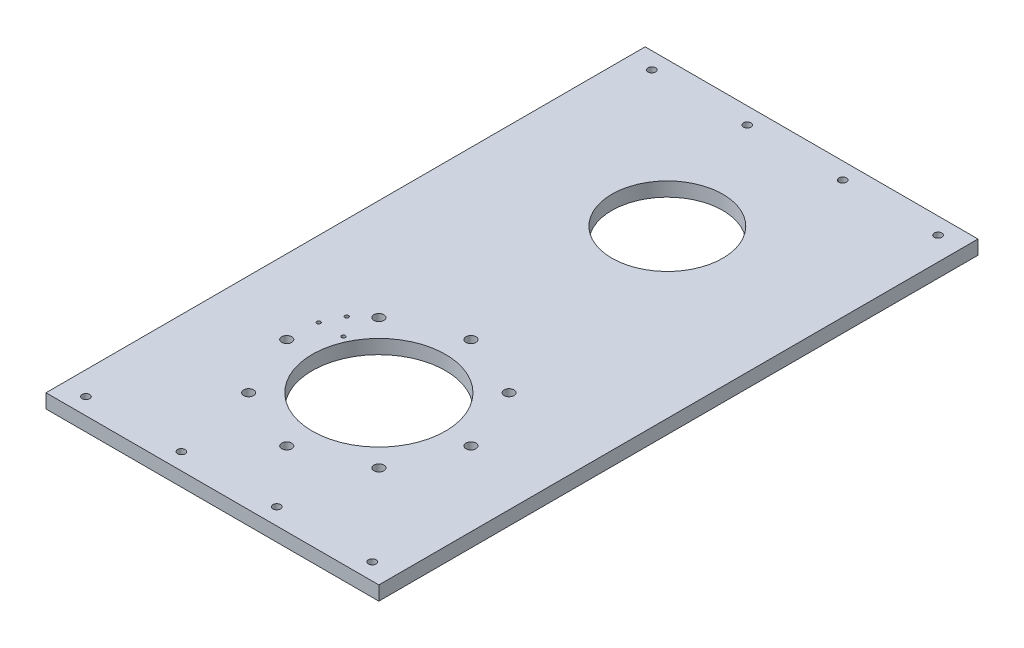
from build123d import *

# Parameters (mm, degrees)
SKETCH1_W           = 150
SKETCH1_H           = 270
BOSS_EXTRUDE1_DEPTH = 6.35
SKETCH2_R           = 2.25
SKETCH2_R_2         = 30
CUT_EXTRUDE1_DEPTH  = 7.35
SKETCH6_R           = 0.85
CUT_EXTRUDE5_DEPTH  = 7.35
SKETCH7_R           = 1.7
CUT_EXTRUDE6_DEPTH  = 7.35
SKETCH8_R           = 25
CUT_EXTRUDE9_DEPTH  = 7.35


with BuildPart() as part:
    # Sketch1 → Boss-Extrude1 (new body)
    with BuildSketch(Plane(origin=(0, 0, 0), x_dir=(1, 0, 0), z_dir=(0, 1, 0))):
        Rectangle(SKETCH1_W, SKETCH1_H)
    extrude(amount=BOSS_EXTRUDE1_DEPTH)

    # Sketch2 → Cut-Extrude1 (cut, through all)
    with BuildSketch(Plane(origin=(0, 6.35, 0), x_dir=(1, 0, 0), z_dir=(0, 1, 0))):
        with Locations((0, -18.5)):
            Circle(SKETCH2_R)
        with Locations((29.344931419, -30.655068581)):
            Circle(SKETCH2_R)
        with Locations((41.5, -60)):
            Circle(SKETCH2_R)
        with Locations((29.344931419, -89.344931419)):
            Circle(SKETCH2_R)
        with Locations((0, -101.5)):
            Circle(SKETCH2_R)
        with Locations((-29.344931419, -89.344931419)):
            Circle(SKETCH2_R)
        with Locations((-41.5, -60)):
            Circle(SKETCH2_R)
        with Locations((-29.344931419, -30.655068581)):
            Circle(SKETCH2_R)
        with Locations((0, -60)):
            Circle(SKETCH2_R_2)
    extrude(amount=-CUT_EXTRUDE1_DEPTH, mode=Mode.SUBTRACT)

    # Sketch6 → Cut-Extrude5 (cut, through all)
    with BuildSketch(Plane(origin=(0, 6.35, 0), x_dir=(1, 0, 0), z_dir=(0, 1, 0))):
        with Locations((-36.963798099, -37.522452757)):
            Circle(SKETCH6_R)
        with Locations((-40.978671586, -46.132376734)):
            Circle(SKETCH6_R)
        with Locations((-29.908156972, -46.053597363)):
            Circle(SKETCH6_R)
    extrude(amount=-CUT_EXTRUDE5_DEPTH, mode=Mode.SUBTRACT)

    # Sketch7 → Cut-Extrude6 (cut, through all)
    with BuildSketch(Plane(origin=(0, 6.35, 0), x_dir=(1, 0, 0), z_dir=(0, 1, 0))):
        with Locations((-64.5, -127.5)):
            Circle(SKETCH7_R)
        with Locations((-21.5, -127.5)):
            Circle(SKETCH7_R)
        with Locations((21.5, -127.5)):
            Circle(SKETCH7_R)
        with Locations((64.5, -127.5)):
            Circle(SKETCH7_R)
        with Locations((64.5, 127.5)):
            Circle(SKETCH7_R)
        with Locations((21.5, 127.5)):
            Circle(SKETCH7_R)
        with Locations((-64.5, 127.5)):
            Circle(SKETCH7_R)
        with Locations((-21.5, 127.5)):
            Circle(SKETCH7_R)
    extrude(amount=-CUT_EXTRUDE6_DEPTH, mode=Mode.SUBTRACT)

    # Sketch8 → Cut-Extrude9 (cut, through all)
    with BuildSketch(Plane(origin=(0, 6.35, 0), x_dir=(1, 0, 0), z_dir=(0, 1, 0))):
        with Locations((0, 70)):
            Circle(SKETCH8_R)
    extrude(amount=-CUT_EXTRUDE9_DEPTH, mode=Mode.SUBTRACT)


solid = part.part
